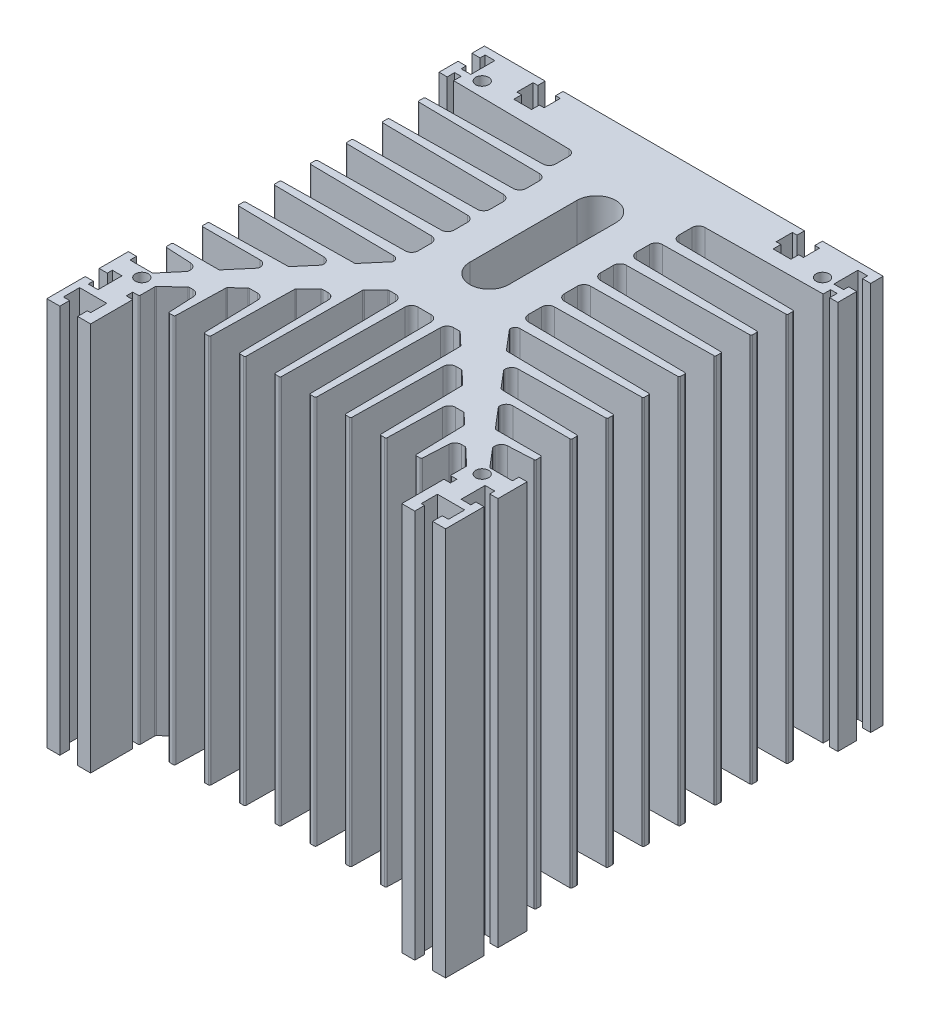
from build123d import *

# Parameters (mm, degrees)
SALIENTE_EXTRUIR1_DEPTH = 120
CORTAR_EXTRUIR1_DEPTH   = 120
REDONDEO1_R             = 0.4
CORTAR_EXTRUIR2_DEPTH   = 121
CORTAR_EXTRUIR3_DEPTH   = 121
REDONDEO2_R             = 0.4
CROQUIS5_R              = 2
CORTAR_EXTRUIR4_DEPTH   = 10


with BuildPart() as part:
    # Croquis1 → Saliente-Extruir1 (new body)
    with BuildSketch(Plane(origin=(0, 0, 0), x_dir=(1, 0, 0), z_dir=(0, 1, 0))):
        Polygon((-61.5, -11.85), (-57.5, -11.85), (-57.5, -8.85), (-59.4, -8.85), (-59.4, -3.85), (-51, -3.85), (-51, -8.85), (-52, -8.85), (-52, -11.85), (-48, -11.85), (-48, 1.15), (-50, 1.15), (-50, 3.15), (50, 3.15), (50, 1.15), (48, 1.15), (48, -11.85), (52, -11.85), (52, -8.85), (51, -8.85), (51, -3.85), (59.4, -3.85), (59.4, -8.85), (57.5, -8.85), (57.5, -11.85), (61.5, -11.85), (61.5, 0), (59, 0), (59, -1.55), (56, -1.55), (56, 5.85), (59, 5.85), (59, 4.3), (61.5, 4.3), (61.5, 13.3), (59, 13.3), (59, 11.3), (57, 11.3), (57, 111.45), (59, 111.45), (59, 109.15), (61.5, 109.15), (61.5, 115), (59, 115), (59, 113.45), (56, 113.45), (56, 120.85), (59, 120.85), (59, 119.3), (61.5, 119.3), (61.5, 123.15), (42.75, 123.15), (42.75, 120.85), (44.2, 120.85), (44.2, 115.85), (42.75, 115.85), (42.75, 113.45), (37.25, 113.45), (37.25, 115.85), (35.8, 115.85), (35.8, 120.85), (37.25, 120.85), (37.25, 123.15), (1, 123.15), (-1, 123.15), (-37.25, 123.15), (-37.25, 120.85), (-35.8, 120.85), (-35.8, 115.85), (-37.25, 115.85), (-37.25, 113.45), (-42.75, 113.45), (-42.75, 115.85), (-44.2, 115.85), (-44.2, 120.85), (-42.75, 120.85), (-42.75, 123.15), (-61.5, 123.15), (-61.5, 119.3), (-59, 119.3), (-59, 120.85), (-56, 120.85), (-56, 113.45), (-59, 113.45), (-59, 115), (-61.5, 115), (-61.5, 109.15), (-59, 109.15), (-59, 111.45), (-57, 111.45), (-57, 11.3), (-59, 11.3), (-59, 13.3), (-61.5, 13.3), (-61.5, 4.3), (-59, 4.3), (-59, 5.85), (-56, 5.85), (-56, -1.55), (-59, -1.55), (-59, 0), (-61.5, 0), align=None)
    extrude(amount=SALIENTE_EXTRUIR1_DEPTH)

    # Croquis2 → Cortar-Extruir1 (cut)
    with BuildSketch(Plane(origin=(0, 120, 0), x_dir=(1, 0, 0), z_dir=(0, 1, 0))):
        with BuildLine():
            Line((-48, 7.934711807), (-48, 3.15))
            Line((-48, 3.15), (-39, 3.15))
            Line((-39, 3.15), (-39.404993762, 11.249875234))
            ThreePointArc((-39.404993762, 11.249875234), (-40.024048308, 12.599094626), (-41.402498439, 13.15))
            Line((-41.402498439, 13.15), (-42.515266767, 13.15))
            ThreePointArc((-42.515266767, 13.15), (-42.700176063, 13.114551991), (-42.858866694, 13.013234208))
            Line((-42.858866694, 13.013234208), (-47.843599927, 8.297946015))
            ThreePointArc((-47.843599927, 8.297946015), (-47.95923848, 8.132449052), (-48, 7.934711807))
        make_face()
        with BuildLine():
            ThreePointArc((-30.573060822, 22.15), (-29.177572866, 21.582694442), (-28.573752983, 20.202613364))
            Line((-28.573752983, 20.202613364), (-28.125, 3.15))
            Line((-28.125, 3.15), (-37.125, 3.15))
            Line((-37.125, 3.15), (-36.71789573, 18.619962257))
            ThreePointArc((-36.71789573, 18.619962257), (-36.674666385, 18.810570095), (-36.561668697, 18.970043124))
            Line((-36.561668697, 18.970043124), (-33.34458098, 22.013234208))
            ThreePointArc((-33.34458098, 22.013234208), (-33.185890349, 22.114551991), (-33.000981053, 22.15))
            Line((-33.000981053, 22.15), (-32.625, 22.15))
            Line((-32.625, 22.15), (-30.573060822, 22.15))
        make_face()
        with BuildLine():
            ThreePointArc((-19.716944425, 33.15), (-18.314563844, 32.575948353), (-17.717222145, 31.183328705))
            Line((-17.717222145, 31.183328705), (-17.25, 3.15))
            Line((-17.25, 3.15), (-26.25, 3.15))
            Line((-26.25, 3.15), (-25.784450219, 28.958362018))
            ThreePointArc((-25.784450219, 28.958362018), (-25.741968108, 29.151214862), (-25.628131475, 29.312578334))
            Line((-25.628131475, 29.312578334), (-21.716009551, 33.013234208))
            ThreePointArc((-21.716009551, 33.013234208), (-21.55731892, 33.114551991), (-21.372409624, 33.15))
            Line((-21.372409624, 33.15), (-19.716944425, 33.15))
        make_face()
        with BuildLine():
            ThreePointArc((-8.968994126, 43.15), (-7.565871247, 42.575217943), (-6.969238222, 41.181246186))
            Line((-6.969238222, 41.181246186), (-6.375, 3.15))
            Line((-6.375, 3.15), (-15.375, 3.15))
            Line((-15.375, 3.15), (-15.037534994, 39.120091838))
            ThreePointArc((-15.037534994, 39.120091838), (-14.995862888, 39.315290379), (-14.881156924, 39.478635342))
            Line((-14.881156924, 39.478635342), (-11.14458098, 43.013234208))
            ThreePointArc((-11.14458098, 43.013234208), (-10.985890349, 43.114551991), (-10.800981053, 43.15))
            Line((-10.800981053, 43.15), (-8.968994126, 43.15))
        make_face()
        with BuildLine():
            Line((-2.024843756, 43.15), (2.024843756, 43.15))
            ThreePointArc((2.024843756, 43.15), (3.430191383, 42.573024261), (4.024687524, 41.174998047))
            Line((4.024687524, 41.174998047), (4.5, 3.15))
            Line((4.5, 3.15), (-4.5, 3.15))
            Line((-4.5, 3.15), (-4.024687524, 41.174998047))
            ThreePointArc((-4.024687524, 41.174998047), (-3.430191383, 42.573024261), (-2.024843756, 43.15))
        make_face()
        with BuildLine():
            Line((11.14458098, 43.013234208), (14.881156924, 39.478635342))
            ThreePointArc((14.881156924, 39.478635342), (14.995862888, 39.315290379), (15.037534994, 39.120091838))
            Line((15.037534994, 39.120091838), (15.375, 3.15))
            Line((15.375, 3.15), (6.375, 3.15))
            Line((6.375, 3.15), (6.969238222, 41.181246186))
            ThreePointArc((6.969238222, 41.181246186), (7.565871247, 42.575217943), (8.968994126, 43.15))
            Line((8.968994126, 43.15), (10.800981053, 43.15))
            ThreePointArc((10.800981053, 43.15), (10.985890349, 43.114551991), (11.14458098, 43.013234208))
        make_face()
        with BuildLine():
            Line((21.716009551, 33.013234208), (25.628131475, 29.312578334))
            ThreePointArc((25.628131475, 29.312578334), (25.741968108, 29.151214862), (25.784450219, 28.958362018))
            Line((25.784450219, 28.958362018), (26.25, 3.15))
            Line((26.25, 3.15), (17.25, 3.15))
            Line((17.25, 3.15), (17.717222145, 31.183328705))
            ThreePointArc((17.717222145, 31.183328705), (18.314563844, 32.575948353), (19.716944425, 33.15))
            Line((19.716944425, 33.15), (21.372409624, 33.15))
            ThreePointArc((21.372409624, 33.15), (21.55731892, 33.114551991), (21.716009551, 33.013234208))
        make_face()
        with BuildLine():
            Line((33.34458098, 22.013234208), (36.561668697, 18.970043124))
            ThreePointArc((36.561668697, 18.970043124), (36.674666385, 18.810570095), (36.71789573, 18.619962257))
            Line((36.71789573, 18.619962257), (37.125, 3.15))
            Line((37.125, 3.15), (28.125, 3.15))
            Line((28.125, 3.15), (28.573752983, 20.202613364))
            ThreePointArc((28.573752983, 20.202613364), (29.177572866, 21.582694442), (30.573060822, 22.15))
            Line((30.573060822, 22.15), (32.625, 22.15))
            Line((32.625, 22.15), (33.000981053, 22.15))
            ThreePointArc((33.000981053, 22.15), (33.185890349, 22.114551991), (33.34458098, 22.013234208))
        make_face()
        with BuildLine():
            Line((42.858866694, 13.013234208), (47.843599927, 8.297946015))
            ThreePointArc((47.843599927, 8.297946015), (47.95923848, 8.132449052), (48, 7.934711807))
            Line((48, 7.934711807), (48, 3.15))
            Line((48, 3.15), (39, 3.15))
            Line((39, 3.15), (39.404993762, 11.249875234))
            ThreePointArc((39.404993762, 11.249875234), (40.024048308, 12.599094626), (41.402498439, 13.15))
            Line((41.402498439, 13.15), (42.515266767, 13.15))
            ThreePointArc((42.515266767, 13.15), (42.700176063, 13.114551991), (42.858866694, 13.013234208))
        make_face()
    extrude(amount=-CORTAR_EXTRUIR1_DEPTH, mode=Mode.SUBTRACT)

    # Redondeo1
    redondeo1_edges = [part.edges().sort_by_distance(p)[0] for p in [
        (-39, 60, -3.15),
        (-48, 60, -3.15),
        (-28.125, 60, -3.15),
        (-37.125, 60, -3.15),
        (-17.25, 60, -3.15),
        (-26.25, 60, -3.15),
        (-6.375, 60, -3.15),
        (-15.375, 60, -3.15),
        (4.5, 60, -3.15),
        (-4.5, 60, -3.15),
        (15.375, 60, -3.15),
        (6.375, 60, -3.15),
        (26.25, 60, -3.15),
        (17.25, 60, -3.15),
        (37.125, 60, -3.15),
        (28.125, 60, -3.15),
        (48, 60, -3.15),
        (39, 60, -3.15),
    ]]
    fillet(redondeo1_edges, radius=REDONDEO1_R)

    # Croquis3 → Cortar-Extruir2 (cut, through all)
    with BuildSketch(Plane(origin=(0, 120, 0), x_dir=(1, 0, 0), z_dir=(0, 1, 0))):
        with BuildLine():
            Line((-57, 109.15), (-57, 100.15))
            Line((-57, 100.15), (-20.973686488, 100.624030441))
            ThreePointArc((-20.973686488, 100.624030441), (-19.576513607, 101.218977805), (-19, 102.623857333))
            Line((-19, 102.623857333), (-19, 106.676142667))
            ThreePointArc((-19, 106.676142667), (-19.576513607, 108.081022195), (-20.973686488, 108.675969559))
            Line((-20.973686488, 108.675969559), (-57, 109.15))
        make_face()
        with BuildLine():
            Line((-57, 98.04375), (-57, 89.04375))
            Line((-57, 89.04375), (-18.975001953, 89.519062476))
            ThreePointArc((-18.975001953, 89.519062476), (-17.576975739, 90.113558617), (-17, 91.518906244))
            Line((-17, 91.518906244), (-17, 95.568593756))
            ThreePointArc((-17, 95.568593756), (-17.576975739, 96.973941383), (-18.975001953, 97.568437524))
            Line((-18.975001953, 97.568437524), (-57, 98.04375))
        make_face()
        with BuildLine():
            Line((-57, 86.9375), (-57, 77.9375))
            Line((-57, 77.9375), (-18.975001953, 78.412812476))
            ThreePointArc((-18.975001953, 78.412812476), (-17.576975739, 79.007308617), (-17, 80.412656244))
            Line((-17, 80.412656244), (-17, 84.462343756))
            ThreePointArc((-17, 84.462343756), (-17.576975739, 85.867691383), (-18.975001953, 86.462187524))
            Line((-18.975001953, 86.462187524), (-57, 86.9375))
        make_face()
        with BuildLine():
            Line((-57, 75.83125), (-57, 66.83125))
            Line((-57, 66.83125), (-18.975001953, 67.306562476))
            ThreePointArc((-18.975001953, 67.306562476), (-17.576975739, 67.901058617), (-17, 69.306406244))
            Line((-17, 69.306406244), (-17, 73.356093756))
            ThreePointArc((-17, 73.356093756), (-17.576975739, 74.761441383), (-18.975001953, 75.355937524))
            Line((-18.975001953, 75.355937524), (-57, 75.83125))
        make_face()
        with BuildLine():
            Line((-57, 64.725), (-57, 55.725))
            Line((-57, 55.725), (-18.975001953, 56.200312476))
            ThreePointArc((-18.975001953, 56.200312476), (-17.576975739, 56.794808617), (-17, 58.200156244))
            Line((-17, 58.200156244), (-17, 62.249843756))
            ThreePointArc((-17, 62.249843756), (-17.576975739, 63.655191383), (-18.975001953, 64.249687524))
            Line((-18.975001953, 64.249687524), (-57, 64.725))
        make_face()
        with BuildLine():
            Line((-57, 11.3), (-52.231464731, 11.3))
            ThreePointArc((-52.231464731, 11.3), (-52.021415465, 11.346260751), (-51.850234346, 11.476482777))
            Line((-51.850234346, 11.476482777), (-47.118769615, 17.05200702))
            ThreePointArc((-47.118769615, 17.05200702), (-47.03063064, 17.203209404), (-47, 17.375524243))
            Line((-47, 17.375524243), (-47, 17.897501561))
            ThreePointArc((-47, 17.897501561), (-47.550905374, 19.275951692), (-48.900124766, 19.895006238))
            Line((-48.900124766, 19.895006238), (-57, 20.3))
            Line((-57, 20.3), (-57, 11.3))
        make_face()
        with BuildLine():
            Line((-57, 31.40625), (-57, 22.40625))
            Line((-57, 22.40625), (-42.806551865, 22.40625))
            ThreePointArc((-42.806551865, 22.40625), (-42.596502599, 22.452510751), (-42.42532148, 22.582732777))
            Line((-42.42532148, 22.582732777), (-37.118769615, 28.835935591))
            ThreePointArc((-37.118769615, 28.835935591), (-37.03063064, 28.987137975), (-37, 29.159452814))
            Line((-37, 29.159452814), (-37, 29.40625))
            ThreePointArc((-37, 29.40625), (-37.585786438, 30.820463562), (-39, 31.40625))
            Line((-39, 31.40625), (-57, 31.40625))
        make_face()
        with BuildLine():
            Line((-57, 53.61875), (-57, 44.61875))
            Line((-57, 44.61875), (-23.555641679, 45.083250852))
            ThreePointArc((-23.555641679, 45.083250852), (-23.349390479, 45.130932882), (-23.181355008, 45.259685412))
            Line((-23.181355008, 45.259685412), (-18.118769615, 51.225399877))
            ThreePointArc((-18.118769615, 51.225399877), (-18.03063064, 51.376602261), (-18, 51.5489171))
            Line((-18, 51.5489171), (-18, 51.6378575))
            ThreePointArc((-18, 51.6378575), (-18.432562933, 52.691697198), (-19.480770811, 53.137734241))
            Line((-19.480770811, 53.137734241), (-57, 53.61875))
        make_face()
        with BuildLine():
            Line((-57, 42.5125), (-57, 33.5125))
            Line((-57, 33.5125), (-32.951061773, 34.007861436))
            ThreePointArc((-32.951061773, 34.007861436), (-32.746648158, 34.056203168), (-32.580128233, 34.184238177))
            Line((-32.580128233, 34.184238177), (-28.118769615, 39.441471305))
            ThreePointArc((-28.118769615, 39.441471305), (-28.03063064, 39.592673689), (-28, 39.764988528))
            Line((-28, 39.764988528), (-28, 40.046685516))
            ThreePointArc((-28, 40.046685516), (-28.573648839, 41.448656402), (-29.965522365, 42.046388317))
            Line((-29.965522365, 42.046388317), (-57, 42.5125))
        make_face()
        with BuildLine():
            Line((51.850234346, 11.476482777), (47.118769615, 17.05200702))
            ThreePointArc((47.118769615, 17.05200702), (47.03063064, 17.203209404), (47, 17.375524243))
            Line((47, 17.375524243), (47, 17.897501561))
            ThreePointArc((47, 17.897501561), (47.550905374, 19.275951692), (48.900124766, 19.895006238))
            Line((48.900124766, 19.895006238), (57, 20.3))
            Line((57, 20.3), (57, 11.3))
            Line((57, 11.3), (52.231464731, 11.3))
            ThreePointArc((52.231464731, 11.3), (52.021415465, 11.346260751), (51.850234346, 11.476482777))
        make_face()
        with BuildLine():
            Line((42.42532148, 22.582732777), (37.118769615, 28.835935591))
            ThreePointArc((37.118769615, 28.835935591), (37.03063064, 28.987137975), (37, 29.159452814))
            Line((37, 29.159452814), (37, 29.40625))
            ThreePointArc((37, 29.40625), (37.585786438, 30.820463562), (39, 31.40625))
            Line((39, 31.40625), (57, 31.40625))
            Line((57, 31.40625), (57, 22.40625))
            Line((57, 22.40625), (42.806551865, 22.40625))
            ThreePointArc((42.806551865, 22.40625), (42.596502599, 22.452510751), (42.42532148, 22.582732777))
        make_face()
        with BuildLine():
            Line((28.118769615, 39.441471305), (32.580128233, 34.184238177))
            ThreePointArc((32.580128233, 34.184238177), (32.746648158, 34.056203168), (32.951061773, 34.007861436))
            Line((32.951061773, 34.007861436), (57, 33.5125))
            Line((57, 33.5125), (57, 42.5125))
            Line((57, 42.5125), (29.965522365, 42.046388317))
            ThreePointArc((29.965522365, 42.046388317), (28.573648839, 41.448656402), (28, 40.046685516))
            Line((28, 40.046685516), (28, 39.764988528))
            ThreePointArc((28, 39.764988528), (28.03063064, 39.592673689), (28.118769615, 39.441471305))
        make_face()
        with BuildLine():
            Line((18.118769615, 51.225399877), (23.181355008, 45.259685412))
            ThreePointArc((23.181355008, 45.259685412), (23.349390479, 45.130932882), (23.555641679, 45.083250852))
            Line((23.555641679, 45.083250852), (57, 44.61875))
            Line((57, 44.61875), (57, 53.61875))
            Line((57, 53.61875), (19.480770811, 53.137734241))
            ThreePointArc((19.480770811, 53.137734241), (18.432562933, 52.691697198), (18, 51.6378575))
            Line((18, 51.6378575), (18, 51.5489171))
            ThreePointArc((18, 51.5489171), (18.03063064, 51.376602261), (18.118769615, 51.225399877))
        make_face()
        with BuildLine():
            Line((57, 55.725), (18.975001953, 56.200312476))
            ThreePointArc((18.975001953, 56.200312476), (17.576975739, 56.794808617), (17, 58.200156244))
            Line((17, 58.200156244), (17, 62.249843756))
            ThreePointArc((17, 62.249843756), (17.576975739, 63.655191383), (18.975001953, 64.249687524))
            Line((18.975001953, 64.249687524), (57, 64.725))
            Line((57, 64.725), (57, 55.725))
        make_face()
        with BuildLine():
            Line((57, 66.83125), (18.975001953, 67.306562476))
            ThreePointArc((18.975001953, 67.306562476), (17.576975739, 67.901058617), (17, 69.306406244))
            Line((17, 69.306406244), (17, 73.356093756))
            ThreePointArc((17, 73.356093756), (17.576975739, 74.761441383), (18.975001953, 75.355937524))
            Line((18.975001953, 75.355937524), (57, 75.83125))
            Line((57, 75.83125), (57, 66.83125))
        make_face()
        with BuildLine():
            Line((57, 77.9375), (18.975001953, 78.412812476))
            ThreePointArc((18.975001953, 78.412812476), (17.576975739, 79.007308617), (17, 80.412656244))
            Line((17, 80.412656244), (17, 84.462343756))
            ThreePointArc((17, 84.462343756), (17.576975739, 85.867691383), (18.975001953, 86.462187524))
            Line((18.975001953, 86.462187524), (57, 86.9375))
            Line((57, 86.9375), (57, 77.9375))
        make_face()
        with BuildLine():
            Line((57, 89.04375), (18.975001953, 89.519062476))
            ThreePointArc((18.975001953, 89.519062476), (17.576975739, 90.113558617), (17, 91.518906244))
            Line((17, 91.518906244), (17, 95.568593756))
            ThreePointArc((17, 95.568593756), (17.576975739, 96.973941383), (18.975001953, 97.568437524))
            Line((18.975001953, 97.568437524), (57, 98.04375))
            Line((57, 98.04375), (57, 89.04375))
        make_face()
        with BuildLine():
            Line((57, 100.15), (20.973686488, 100.624030441))
            ThreePointArc((20.973686488, 100.624030441), (19.576513607, 101.218977805), (19, 102.623857333))
            Line((19, 102.623857333), (19, 106.676142667))
            ThreePointArc((19, 106.676142667), (19.576513607, 108.081022195), (20.973686488, 108.675969559))
            Line((20.973686488, 108.675969559), (57, 109.15))
            Line((57, 109.15), (57, 100.15))
        make_face()
    extrude(amount=-CORTAR_EXTRUIR2_DEPTH, mode=Mode.SUBTRACT)

    # Croquis4 → Cortar-Extruir3 (cut, through all)
    with BuildSketch(Plane(origin=(0, 120, 0), x_dir=(1, 0, 0), z_dir=(0, 1, 0))):
        with BuildLine():
            Line((6, 96.15), (6, 63.15))
            ThreePointArc((6, 63.15), (0, 57.15), (-6, 63.15))
            Line((-6, 63.15), (-6, 96.15))
            ThreePointArc((-6, 96.15), (0, 102.15), (6, 96.15))
        make_face()
    extrude(amount=-CORTAR_EXTRUIR3_DEPTH, mode=Mode.SUBTRACT)

    # Redondeo2
    redondeo2_edges = [part.edges().sort_by_distance(p)[0] for p in [
        (-57, 60, -98.04375),
        (-57, 60, -89.04375),
        (-57, 60, -86.9375),
        (-57, 60, -77.9375),
        (-57, 60, -75.83125),
        (-57, 60, -66.83125),
        (-57, 60, -64.725),
        (-57, 60, -55.725),
        (-57, 60, -20.3),
        (-57, 60, -31.40625),
        (-57, 60, -22.40625),
        (-57, 60, -53.61875),
        (-57, 60, -44.61875),
        (-57, 60, -42.5125),
        (-57, 60, -33.5125),
        (57, 60, -20.3),
        (57, 60, -98.04375),
        (57, 60, -89.04375),
        (57, 60, -86.9375),
        (57, 60, -77.9375),
        (57, 60, -75.83125),
        (57, 60, -66.83125),
        (57, 60, -31.40625),
        (57, 60, -22.40625),
        (57, 60, -42.5125),
        (57, 60, -33.5125),
        (57, 60, -53.61875),
        (57, 60, -44.61875),
        (57, 60, -100.15),
        (57, 60, -64.725),
        (57, 60, -55.725),
        (-57, 60, -100.15),
    ]]
    fillet(redondeo2_edges, radius=REDONDEO2_R)

    # Croquis5 → Cortar-Extruir4 (cut)
    with BuildSketch(Plane(origin=(0, 120, 0), x_dir=(1, 0, 0), z_dir=(0, 1, 0))):
        with Locations((-52.5, 8.45)):
            Circle(CROQUIS5_R)
        with Locations((-52.5, 113.45)):
            Circle(CROQUIS5_R)
        with Locations((52.5, 113.45)):
            Circle(CROQUIS5_R)
        with Locations((52.5, 8.45)):
            Circle(CROQUIS5_R)
    extrude(amount=-CORTAR_EXTRUIR4_DEPTH, mode=Mode.SUBTRACT)


solid = part.part
